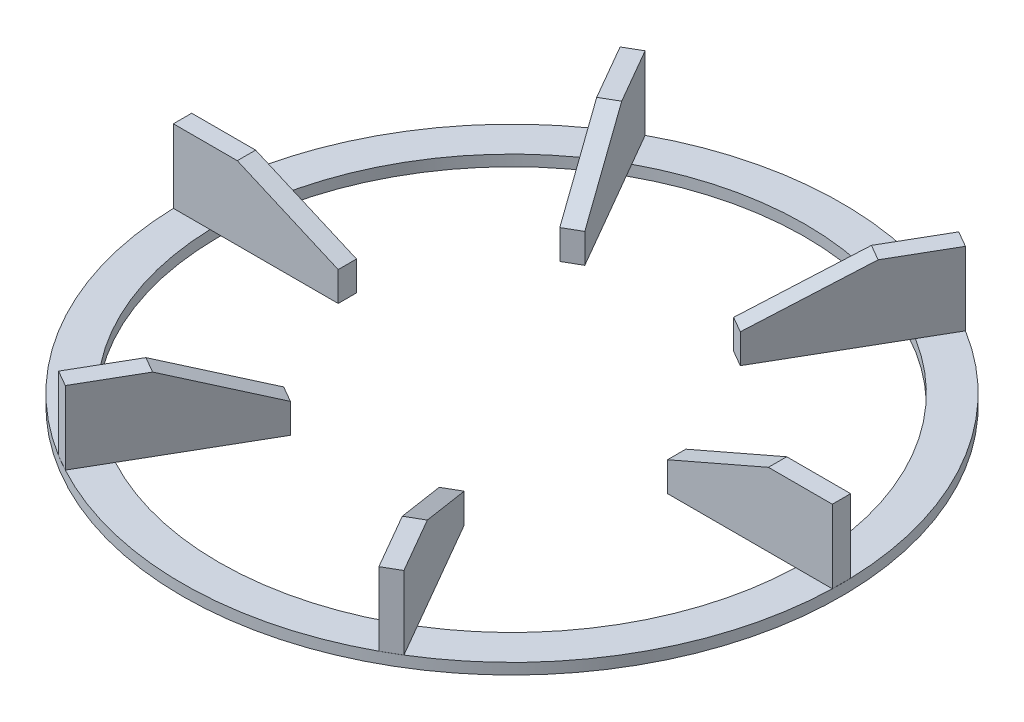
from build123d import *

# Parameters (mm, degrees)
SKETCH1_R           = 90
SKETCH1_R_2         = 80
EXTRUDE_THIN1_DEPTH = 3
SKETCH2_W           = 45
SKETCH2_H           = 5
BOSS_EXTRUDE1_DEPTH = 20
CUT_EXTRUDE1_DEPTH  = 5
CIRPATTERN1_COUNT   = 6
SCALE1_SCALE        = 1.25


with BuildPart() as part:
    # Sketch1 → Extrude-Thin1 (new body)
    with BuildSketch(Plane(origin=(0, 0, 0), x_dir=(1, 0, 0), z_dir=(0, 1, 0))):
        Circle(SKETCH1_R)
        Circle(SKETCH1_R_2, mode=Mode.SUBTRACT)
    extrude(amount=EXTRUDE_THIN1_DEPTH)

    # Sketch2 → Boss-Extrude1 (add)
    with BuildSketch(Plane(origin=(0, 3, 0), x_dir=(1, 0, 0), z_dir=(0, 1, 0))):
        with Locations((67.465271077, 0)):
            Rectangle(SKETCH2_W, SKETCH2_H)
    boss_extrude1 = extrude(amount=BOSS_EXTRUDE1_DEPTH)

    # Sketch3 → Cut-Extrude1 (cut)
    with BuildSketch(Plane.XY.offset(2.5)):
        Polygon((44.965271077, 11.022693862), (72.510497513, 23), (44.965271077, 23), align=None)
    cut_extrude1 = extrude(amount=-CUT_EXTRUDE1_DEPTH, mode=Mode.SUBTRACT)

    # CirPattern1: Boss-Extrude1, Cut-Extrude1 ×6 about axis
    cirpattern1_axis = Axis((0, 0, 0), (0, 1, 0))
    for i in range(1, CIRPATTERN1_COUNT):
        add(boss_extrude1.rotate(cirpattern1_axis, i * 360 / CIRPATTERN1_COUNT))
        add(cut_extrude1.rotate(cirpattern1_axis, i * 360 / CIRPATTERN1_COUNT), mode=Mode.SUBTRACT)


with BuildPart() as part_1:
    # Scale1: scaled about (0, 7.379680738, 0)
    add(part.part.scale(SCALE1_SCALE).moved(Location((0, -1.844920185, 0))))


solid = part_1.part
